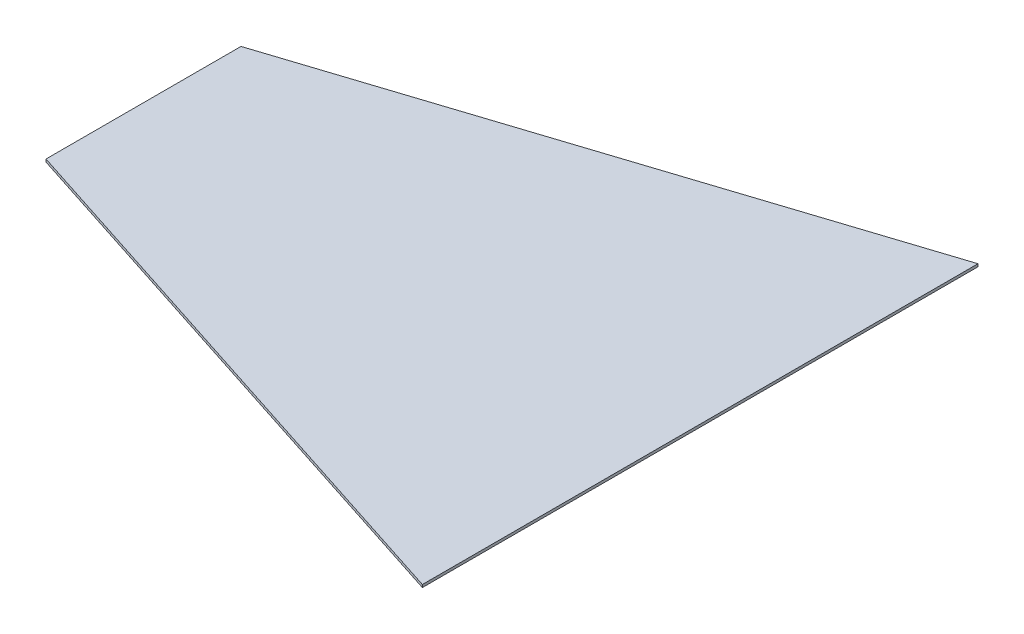
from build123d import *

# Parameters (mm, degrees)
SKETCH1_W           = 529.336
SKETCH1_H           = 528.32
BOSS_EXTRUDE1_DEPTH = 2.54
CUT_EXTRUDE1_DEPTH  = 2.54


with BuildPart() as part:
    # Sketch1 → Boss-Extrude1 (new body)
    with BuildSketch(Plane(origin=(0, 0, 0), x_dir=(1, 0, 0), z_dir=(0, 1, 0))):
        with Locations((31.744757974, -202.68532833)):
            Rectangle(SKETCH1_W, SKETCH1_H)
    extrude(amount=BOSS_EXTRUDE1_DEPTH)

    # Sketch2 → Cut-Extrude1 (cut)
    with BuildSketch(Plane(origin=(0, 2.54, 0), x_dir=(1, 0, 0), z_dir=(0, 1, 0))):
        Polygon((296.412757974, -466.84532833), (-232.923242026, -295.39532833), (-232.923242026, -466.84532833), align=None)
        Polygon((296.412757974, 61.47467167), (-232.923242026, -109.97532833), (-232.923242026, 61.47467167), align=None)
    extrude(amount=-CUT_EXTRUDE1_DEPTH, mode=Mode.SUBTRACT)


solid = part.part
